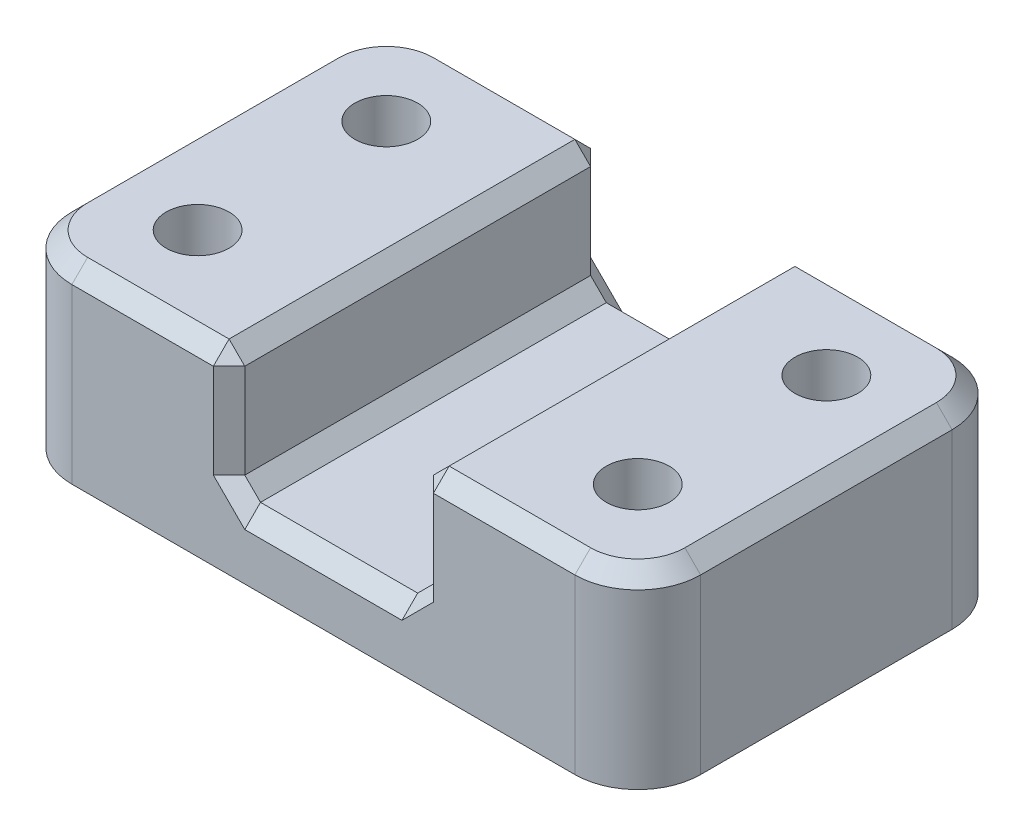
from build123d import *

# Parameters (mm, degrees)
SKETCH2_W           = 127
SKETCH2_H           = 76.2
SKETCH2_R           = 6.35
BOSS_EXTRUDE1_DEPTH = 38.1
SKETCH3_W           = 38.1
SKETCH3_H           = 76.2
CUT_EXTRUDE1_DEPTH  = 25.4
FILLET1_R           = 12.7
CHAMFER1_SIZE       = 3.175


with BuildPart() as part:
    # Sketch2 → Boss-Extrude1 (new body)
    with BuildSketch(Plane(origin=(0, 0, 0), x_dir=(1, 0, 0), z_dir=(0, 1, 0))):
        Rectangle(SKETCH2_W, SKETCH2_H)
        with Locations((-44.45, 19.05)):
            Circle(SKETCH2_R, mode=Mode.SUBTRACT)
        with Locations((44.45, 19.05)):
            Circle(SKETCH2_R, mode=Mode.SUBTRACT)
        with Locations((44.45, -19.05)):
            Circle(SKETCH2_R, mode=Mode.SUBTRACT)
        with Locations((-44.45, -19.05)):
            Circle(SKETCH2_R, mode=Mode.SUBTRACT)
    extrude(amount=BOSS_EXTRUDE1_DEPTH)

    # Sketch3 → Cut-Extrude1 (cut)
    with BuildSketch(Plane(origin=(0, 38.1, 0), x_dir=(1, 0, 0), z_dir=(0, 1, 0))):
        Rectangle(SKETCH3_W, SKETCH3_H)
    extrude(amount=-CUT_EXTRUDE1_DEPTH, mode=Mode.SUBTRACT)

    # Fillet1
    fillet1_edges = [part.edges().sort_by_distance(p)[0] for p in [
        (63.5, 19.05, 38.1),
        (-63.5, 19.05, 38.1),
        (-63.5, 19.05, -38.1),
        (63.5, 19.05, -38.1),
    ]]
    fillet(fillet1_edges, radius=FILLET1_R)

    # Chamfer1
    chamfer1_edges = [part.edges().sort_by_distance(p)[0] for p in [
        (34.925, 38.1, 38.1),
        (-34.925, 38.1, -38.1),
        (19.05, 12.7, 0),
        (19.05, 25.4, -38.1),
        (0, 12.7, 38.1),
        (19.05, 25.4, 38.1),
        (-19.05, 12.7, 0),
        (-19.05, 25.4, 38.1),
        (0, 12.7, -38.1),
        (-19.05, 25.4, -38.1),
        (19.05, 38.1, 0),
        (-19.05, 38.1, 0),
        (-34.925, 38.1, 38.1),
        (-63.5, 38.1, 0),
        (-59.780256121, 38.1, -34.380256121),
        (-59.780256121, 38.1, 34.380256121),
        (34.925, 38.1, -38.1),
        (63.5, 38.1, 0),
        (59.780256121, 38.1, 34.380256121),
        (59.780256121, 38.1, -34.380256121),
    ]]
    chamfer(chamfer1_edges, length=CHAMFER1_SIZE)


solid = part.part
